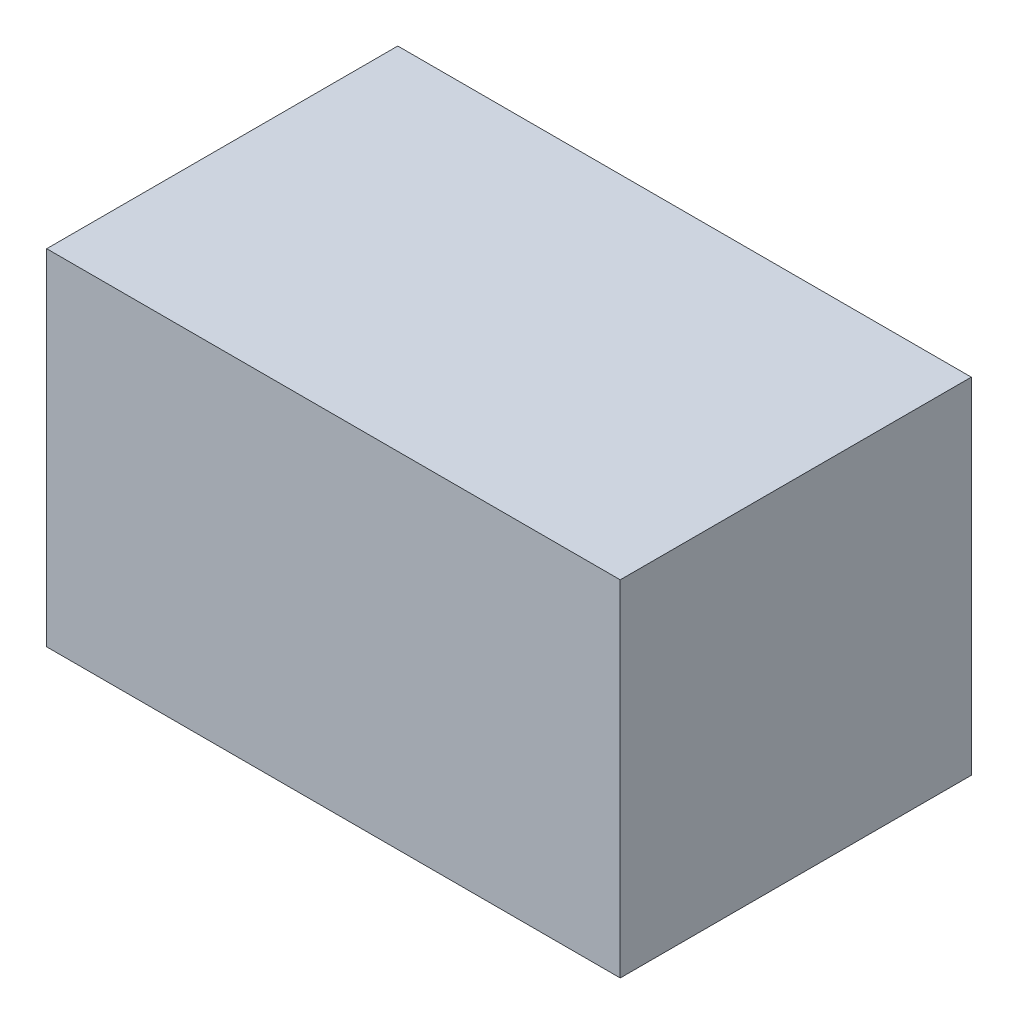
from build123d import *

# Parameters (mm, degrees)
SKETCH_2_W      = 32.1
SKETCH_2_H      = 19.3
EXTRUDE_1_DEPTH = 19.649


with BuildPart() as part:
    # 草图2 → 凸台-拉伸1 (new body)
    with BuildSketch(Plane(origin=(0, 0, 158.149), x_dir=(-1, 0, 0), z_dir=(0, 0, -1))):
        with Locations((68.401953388, 9.346599585)):
            Rectangle(SKETCH_2_W, SKETCH_2_H)
    extrude(amount=EXTRUDE_1_DEPTH)


solid = part.part
